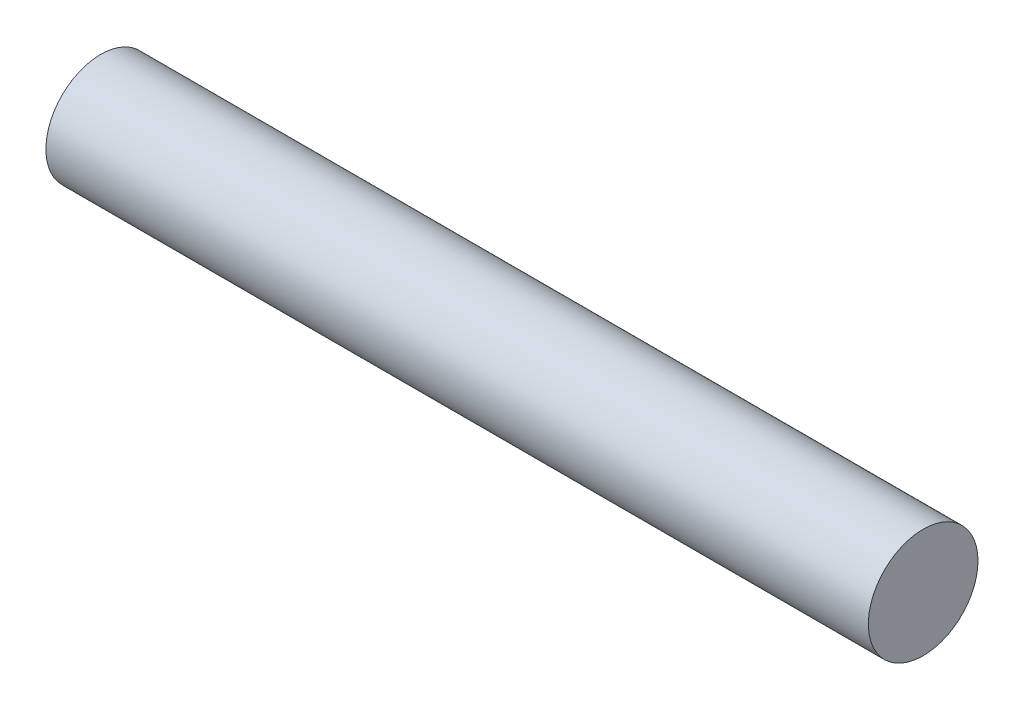
from build123d import *

# Parameters (mm, degrees)
RESSALTO_EXTRUS_O1_DEPTH      = 30
RESSALTO_EXTRUS_O1_DEPTH_BACK = 30
ESBO_O1_R                     = 4


with BuildPart() as part:
    # Esboço1 → Ressalto-extrusão1 (new, two sides: drawn at the far end of the back side and taken through both)
    with BuildSketch(Plane(origin=(0, 0, 0), x_dir=(0, 0, -1), z_dir=(1, 0, 0)).offset(-RESSALTO_EXTRUS_O1_DEPTH_BACK)):
        Circle(ESBO_O1_R)
    extrude(amount=RESSALTO_EXTRUS_O1_DEPTH + RESSALTO_EXTRUS_O1_DEPTH_BACK)


solid = part.part
